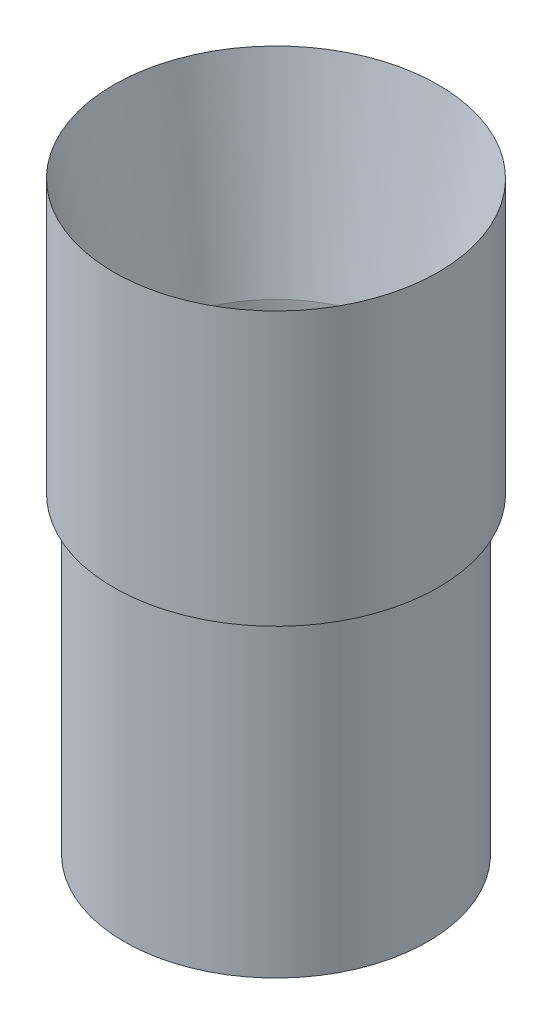
from build123d import *


with BuildPart() as part:
    # Sketch1 → Revolve1 (revolve)
    with BuildSketch(Plane.XY):
        Polygon((2.032, 0), (0, 0), (0, 101.6), (-3.4544, 101.6), (-3.4544, 190.5), (7.742363275, 127), (7.742363275, 101.6), (2.032, 101.6), align=None)
    revolve(axis=Axis((49.3776, 245.641517485, 0), (0, -1, 0)))


solid = part.part
